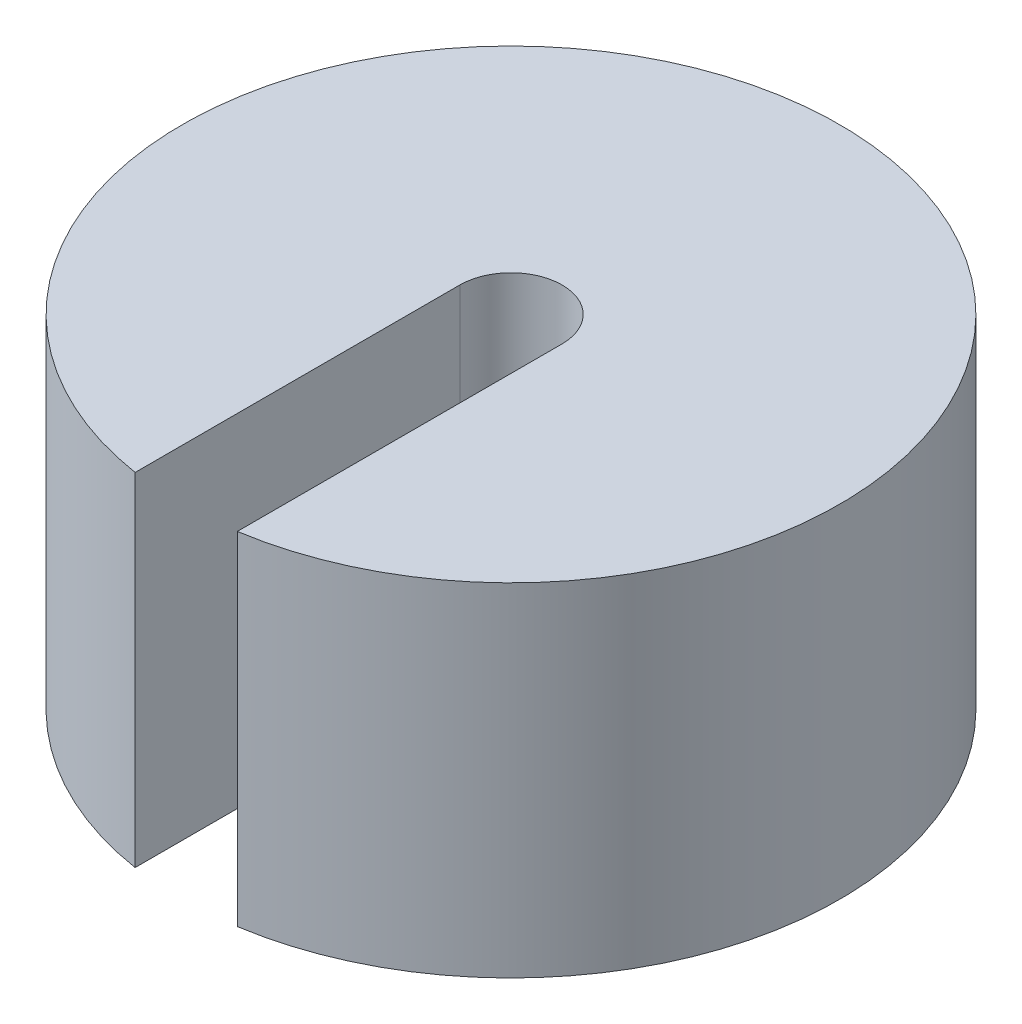
from build123d import *

# Parameters (mm, degrees)
SKETCH2_R           = 20.75
BOSS_EXTRUDE1_DEPTH = 21.6
CUT_EXTRUDE1_DEPTH  = 60.6


with BuildPart() as part:
    # Sketch2 → Boss-Extrude1 (new body)
    with BuildSketch(Plane(origin=(0, 0, 0), x_dir=(1, 0, 0), z_dir=(0, 1, 0))):
        Circle(SKETCH2_R)
    extrude(amount=BOSS_EXTRUDE1_DEPTH)

    # Sketch3 → Cut-Extrude1 (cut)
    with BuildSketch(Plane(origin=(0, 21.6, 0), x_dir=(1, 0, 0), z_dir=(0, 1, 0))):
        with BuildLine():
            Line((-3.225, 0), (-3.225, -21.909989387))
            Line((-3.225, -21.909989387), (3.225, -21.909989387))
            Line((3.225, -21.909989387), (3.225, 0))
            ThreePointArc((3.225, 0), (0, 3.225), (-3.225, 0))
        make_face()
    extrude(amount=-CUT_EXTRUDE1_DEPTH, mode=Mode.SUBTRACT)


solid = part.part
